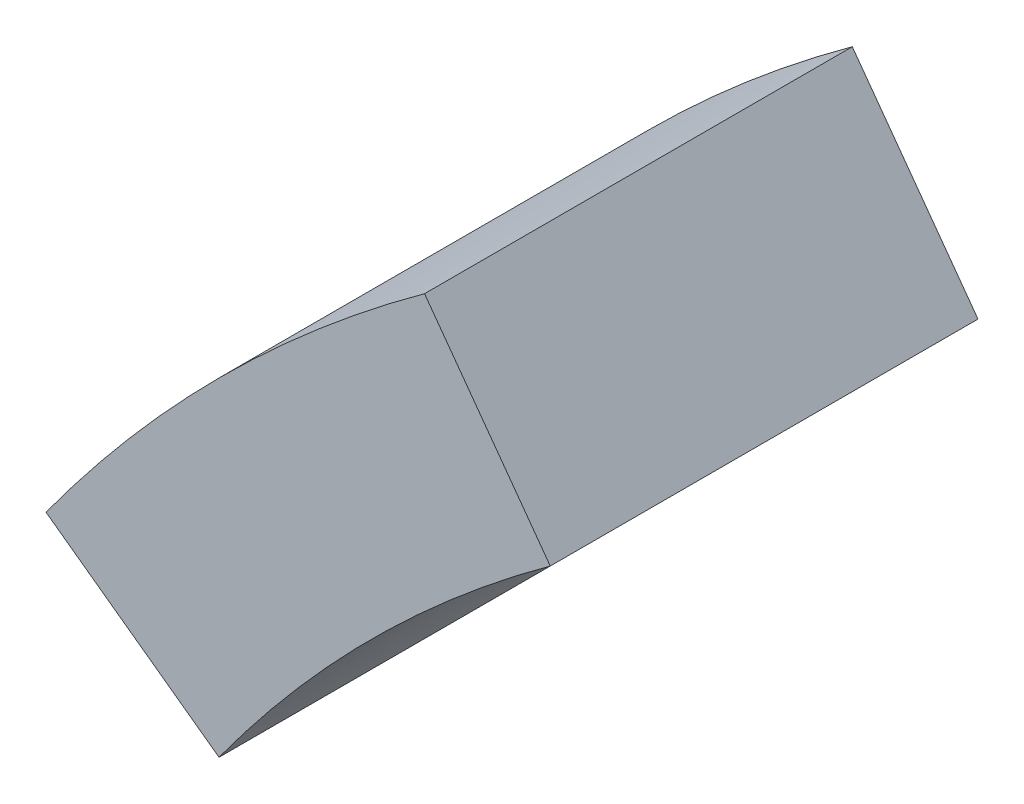
from build123d import *

# Parameters (mm, degrees)
EXTRUDE_1_DEPTH = 480
SCALE_1_SCALE   = 1.3


with BuildPart() as part:
    # 草图1 → 凸台-拉伸1 (new body)
    with BuildSketch(Plane.XY):
        with BuildLine():
            Line((-7793.3126292, 4968.547684402), (-7599.14855055, 4827.479223851))
            ThreePointArc((-7599.14855055, 4827.479223851), (-7427.939392393, 5027.939392393), (-7227.479223851, 5199.14855055))
            Line((-7227.479223851, 5199.14855055), (-7368.547684402, 5393.3126292))
            ThreePointArc((-7368.547684402, 5393.3126292), (-7531.058159836, 5261.115346452), (-7678.198873592, 5112))
            ThreePointArc((-7678.198873592, 5112), (-7737.474510483, 5041.653065761), (-7793.3126292, 4968.547684402))
        make_face()
    extrude(amount=EXTRUDE_1_DEPTH)


with BuildPart() as part_1:
    # 缩放比例1: scaled about (0, 0, 0)
    add(part.part.scale(SCALE_1_SCALE))


solid = part_1.part
